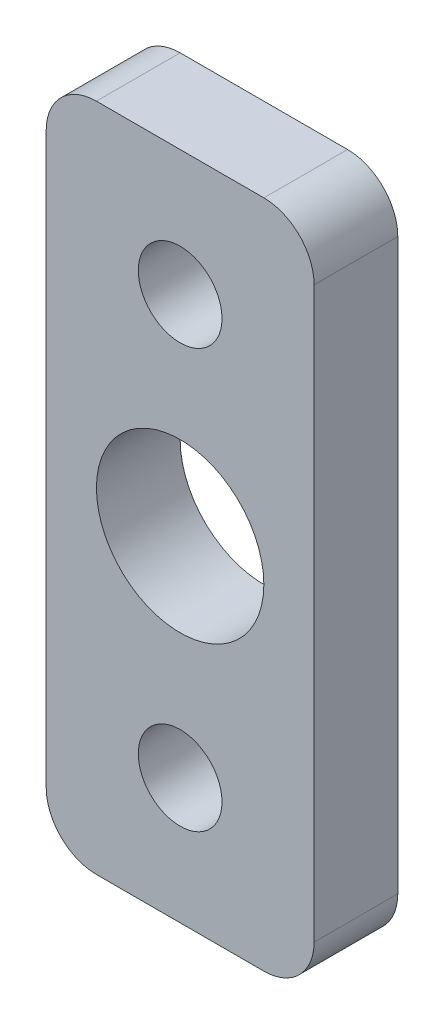
from build123d import *

# Parameters (mm, degrees)
SKETCH_1_W      = 16
SKETCH_1_H      = 40
SKETCH_1_R      = 2.5
SKETCH_1_R_2    = 5
EXTRUDE_1_DEPTH = 5
FILLET_1_R      = 3


with BuildPart() as part:
    # 草图1 → 凸台-拉伸1 (new body)
    with BuildSketch(Plane.XY):
        with Locations((0, 12.5)):
            Rectangle(SKETCH_1_W, SKETCH_1_H)
        with Locations((0, 25)):
            Circle(SKETCH_1_R, mode=Mode.SUBTRACT)
        Circle(SKETCH_1_R, mode=Mode.SUBTRACT)
        with Locations((0, 12.5)):
            Circle(SKETCH_1_R_2, mode=Mode.SUBTRACT)
    extrude(amount=EXTRUDE_1_DEPTH)

    # 圆角1
    fillet_1_edges = [part.edges().sort_by_distance(p)[0] for p in [
        (8, -7.5, 2.5),
        (-8, -7.5, 2.5),
        (-8, 32.5, 2.5),
        (8, 32.5, 2.5),
    ]]
    fillet(fillet_1_edges, radius=FILLET_1_R)


solid = part.part
